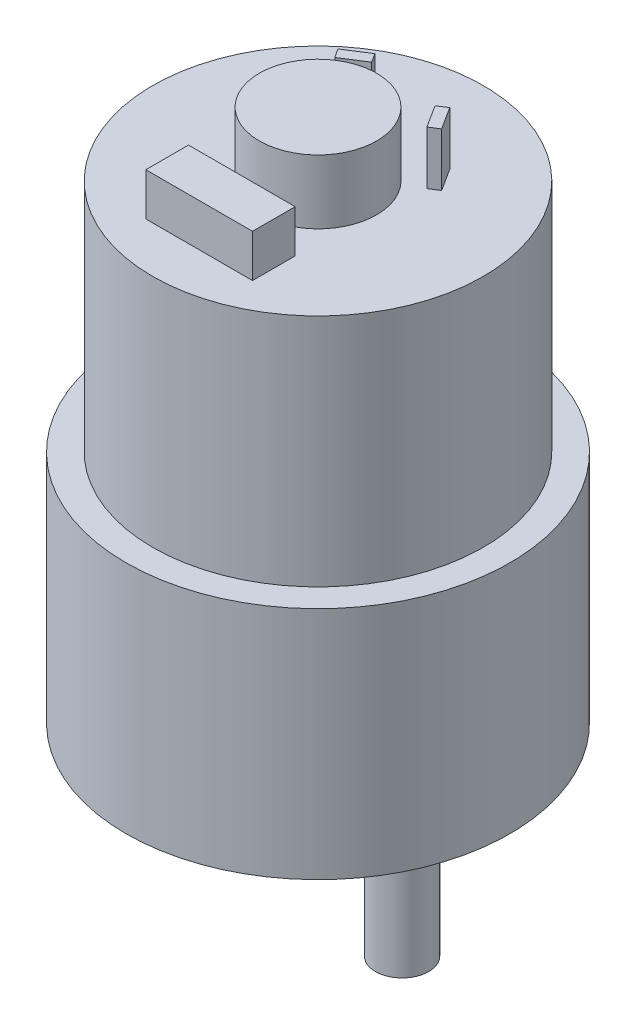
from build123d import *

# Parameters (mm, degrees)
SKETCH_1_R        = 18
EXTRUDE_1_DEPTH   = 22
SKETCH_2_R        = 15.5
EXTRUDE_2_DEPTH   = 22
SKETCH_3_R        = 5
EXTRUDE_4_DEPTH   = 3
SKETCH_4_R        = 2.5
EXTRUDE_5_DEPTH   = 12
SKETCH_5_R        = 5.5
EXTRUDE_6_DEPTH   = 6
EXTRUDE_1_2_DEPTH = 5.003884266
SKETCH_7_W        = 10
SKETCH_7_H        = 4
EXTRUDE_7_DEPTH   = 4


with BuildPart() as part:
    # 草图1 → Extrude 1 (new body)
    with BuildSketch(Plane(origin=(0, 0, 0), x_dir=(1, 0, 0), z_dir=(0, 1, 0))):
        Circle(SKETCH_1_R)
    extrude(amount=EXTRUDE_1_DEPTH)

    # 草图2 → 凸台-拉伸2 (add)
    with BuildSketch(Plane(origin=(0, 22, 0), x_dir=(1, 0, 0), z_dir=(0, 1, 0))):
        Circle(SKETCH_2_R)
    extrude(amount=EXTRUDE_2_DEPTH)

    # 草图3 → 凸台-拉伸4 (add)
    with BuildSketch(Plane.XZ):
        with Locations((7.987474049, 0)):
            Circle(SKETCH_3_R)
    extrude(amount=EXTRUDE_4_DEPTH)

    # 草图4 → 凸台-拉伸5 (add)
    with BuildSketch(Plane.XZ.offset(3)):
        with Locations((7.884702341, 0)):
            Circle(SKETCH_4_R)
    extrude(amount=EXTRUDE_5_DEPTH)

    # 草图5 → 凸台-拉伸6 (add)
    with BuildSketch(Plane(origin=(0, 44, 0), x_dir=(1, 0, 0), z_dir=(0, 1, 0))):
        Circle(SKETCH_5_R)
    extrude(amount=EXTRUDE_6_DEPTH)

    # 草图6 → Extrude 1 2 (add)
    with BuildSketch(Plane(origin=(0, 44, 0), x_dir=(1, 0, 0), z_dir=(0, 1, 0))):
        Polygon((-4.778535484, 6.653759351), (-2.666405598, 8.001927364), (-2.128370145, 7.159005154), (-4.240500031, 5.810837142), align=None)
        Polygon((5.223428842, 7.129609036), (6.568517474, 5.022303512), (5.725595265, 4.484268059), (4.380506633, 6.591573583), align=None)
    extrude(amount=EXTRUDE_1_2_DEPTH)

    # 草图7 → 凸台-拉伸7 (add)
    with BuildSketch(Plane(origin=(0, 44, 0), x_dir=(1, 0, 0), z_dir=(0, 1, 0))):
        with Locations((0.014439493, -9.155250873)):
            Rectangle(SKETCH_7_W, SKETCH_7_H)
    extrude(amount=EXTRUDE_7_DEPTH)


solid = part.part
